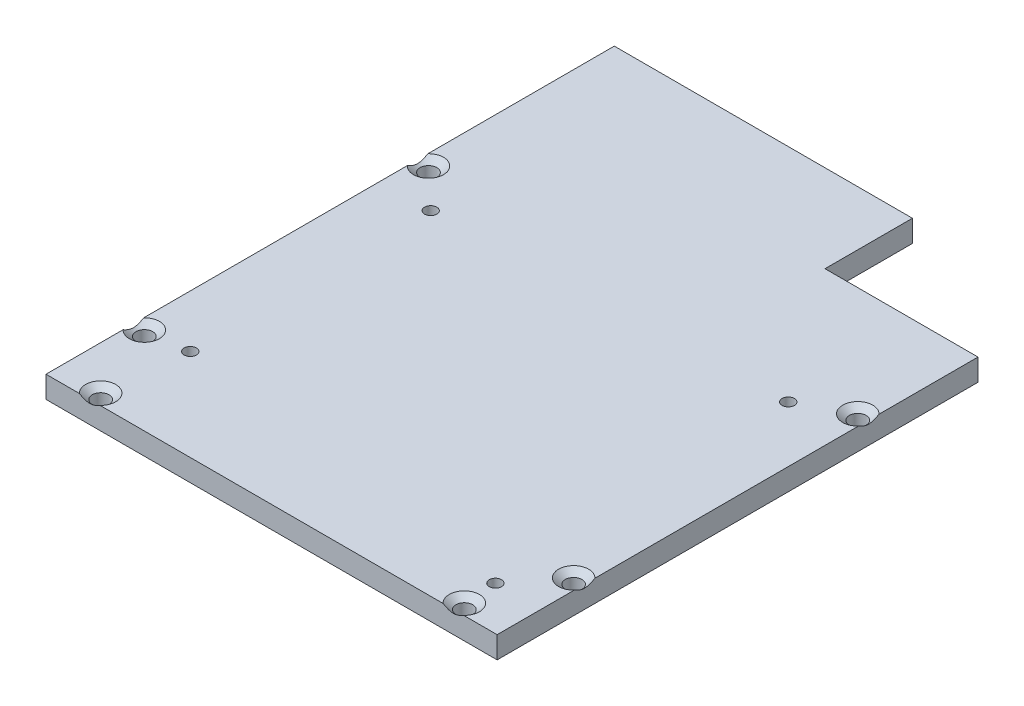
from build123d import *

# Parameters (mm, degrees)
SKETCH1_W                                         = 65.532
SKETCH1_H                                         = 82.55
EXTRUDE1_DEPTH                                    = 3.175
CSK_FOR_2_FLAT_HEAD_MACHINE_SCREW_100_D           = 2.4384
CSK_FOR_2_FLAT_HEAD_MACHINE_SCREW_100_CSINK_D     = 4.3688
CSK_FOR_2_FLAT_HEAD_MACHINE_SCREW_100_CSINK_ANGLE = 100
SKETCH3_W                                         = 22.225
SKETCH3_H                                         = 12.7
CUT_EXTRUDE1_DEPTH                                = 4.175
TAP_DRILL_FOR_2_TAP1_D                            = 1.778
TAP_DRILL_FOR_2_TAP1_DEPTH                        = 6.35
TAP_DRILL_FOR_2_TAP1_TIP                          = 0.53416509


with BuildPart() as part:
    # Sketch1 → Extrude1 (new body)
    with BuildSketch(Plane(origin=(0, 0, 0), x_dir=(1, 0, 0), z_dir=(0, 1, 0))):
        with Locations((0, 7.9375)):
            Rectangle(SKETCH1_W, SKETCH1_H)
    extrude(amount=EXTRUDE1_DEPTH)

    # CSK for #2 Flat Head Machine Screw (100)1 (through all)
    with Locations(Plane(origin=(-26.416, 3.175, 31.75), x_dir=(0, 0, 1), z_dir=(0, 1, 0))):
        with Locations((0, 0), (0, 52.832), (-52.387499988, -4.7625), (-11.1125, -4.7625), (-52.3875, 57.5945), (-11.1125, 57.5945)):
            CounterSinkHole(CSK_FOR_2_FLAT_HEAD_MACHINE_SCREW_100_D / 2, CSK_FOR_2_FLAT_HEAD_MACHINE_SCREW_100_CSINK_D / 2, counter_sink_angle=CSK_FOR_2_FLAT_HEAD_MACHINE_SCREW_100_CSINK_ANGLE)

    # Sketch3 → Cut-Extrude1 (cut, through all)
    with BuildSketch(Plane(origin=(0, 3.175, 0), x_dir=(-1, 0, 0), z_dir=(0, 1, 0))):
        with Locations((-21.6535, -42.8625)):
            Rectangle(SKETCH3_W, SKETCH3_H)
    extrude(amount=-CUT_EXTRUDE1_DEPTH, mode=Mode.SUBTRACT)

    # Tap Drill for #2 Tap1
    with Locations(Plane(origin=(24.638, 0, -17.0815), x_dir=(0, 0, -1), z_dir=(0, -1, 0))):
        with Locations((0, 0), (-1.905, -50.038), (-37.084, -49.784), (-44.069, 1.524)):
            Hole(TAP_DRILL_FOR_2_TAP1_D / 2, depth=TAP_DRILL_FOR_2_TAP1_DEPTH)
            with Locations((0, 0, -(TAP_DRILL_FOR_2_TAP1_DEPTH + TAP_DRILL_FOR_2_TAP1_TIP / 2))):  # 118° drill point
                Cone(0, TAP_DRILL_FOR_2_TAP1_D / 2, TAP_DRILL_FOR_2_TAP1_TIP, mode=Mode.SUBTRACT)


solid = part.part
